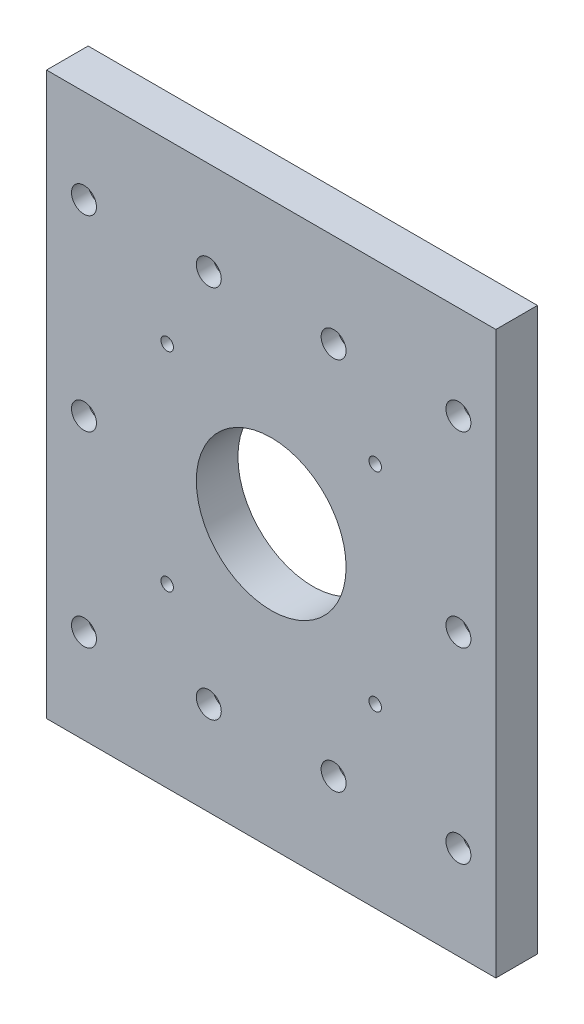
from build123d import *

# Parameters (mm, degrees)
SKETCH1_R          = 3
SKETCH1_R_2        = 1.5
EXTRUDE1_DEPTH     = 10
SKETCH2_R          = 5
CUT_EXTRUDE1_DEPTH = 6
SKETCH3_R          = 18
CUT_EXTRUDE2_DEPTH = 20


with BuildPart() as part:
    # Sketch1 → Extrude1 (new body)
    with BuildSketch(Plane.XY):
        Polygon((5, 135), (0, 135), (-24, 135), (-34, 135), (-34, 0), (-24, 0), (0, 0), (40, 0), (64, 0), (74, 0), (74, 135), (64, 135), (40, 135), align=None)
        with Locations((-25, 22.5)):
            Circle(SKETCH1_R, mode=Mode.SUBTRACT)
        with Locations((5, 22.5)):
            Circle(SKETCH1_R, mode=Mode.SUBTRACT)
        with Locations((-5, 42.5)):
            Circle(SKETCH1_R_2, mode=Mode.SUBTRACT)
        with Locations((35, 22.5)):
            Circle(SKETCH1_R, mode=Mode.SUBTRACT)
        with Locations((65, 22.5)):
            Circle(SKETCH1_R, mode=Mode.SUBTRACT)
        with Locations((45, 42.5)):
            Circle(SKETCH1_R_2, mode=Mode.SUBTRACT)
        with Locations((-25, 67.5)):
            Circle(SKETCH1_R, mode=Mode.SUBTRACT)
        with Locations((-5, 92.5)):
            Circle(SKETCH1_R_2, mode=Mode.SUBTRACT)
        with Locations((-25, 112.5)):
            Circle(SKETCH1_R, mode=Mode.SUBTRACT)
        with Locations((5, 112.5)):
            Circle(SKETCH1_R, mode=Mode.SUBTRACT)
        with Locations((45, 92.5)):
            Circle(SKETCH1_R_2, mode=Mode.SUBTRACT)
        with Locations((65, 67.5)):
            Circle(SKETCH1_R, mode=Mode.SUBTRACT)
        with Locations((35, 112.5)):
            Circle(SKETCH1_R, mode=Mode.SUBTRACT)
        with Locations((65, 112.5)):
            Circle(SKETCH1_R, mode=Mode.SUBTRACT)
    extrude(amount=EXTRUDE1_DEPTH)

    # Sketch2 → Cut-Extrude1 (cut)
    with BuildSketch(Plane(origin=(0, 0, 0), x_dir=(-1, 0, 0), z_dir=(0, 0, -1))):
        with Locations((-35, 112.5)):
            Circle(SKETCH2_R)
        with Locations((-65, 112.5)):
            Circle(SKETCH2_R)
        with Locations((-65, 22.5)):
            Circle(SKETCH2_R)
        with Locations((-5, 112.5)):
            Circle(SKETCH2_R)
        with Locations((-35, 22.5)):
            Circle(SKETCH2_R)
        with Locations((25, 22.5)):
            Circle(SKETCH2_R)
        with Locations((25, 112.5)):
            Circle(SKETCH2_R)
        with Locations((-5, 22.5)):
            Circle(SKETCH2_R)
        with Locations((-65, 67.5)):
            Circle(SKETCH2_R)
        with Locations((25, 67.5)):
            Circle(SKETCH2_R)
    extrude(amount=-CUT_EXTRUDE1_DEPTH, mode=Mode.SUBTRACT)

    # Sketch3 → Cut-Extrude2 (cut)
    with BuildSketch(Plane(origin=(0, 0, 0), x_dir=(-1, 0, 0), z_dir=(0, 0, -1))):
        with Locations((-20, 67.5)):
            Circle(SKETCH3_R)
    extrude(amount=-CUT_EXTRUDE2_DEPTH, mode=Mode.SUBTRACT)


solid = part.part
